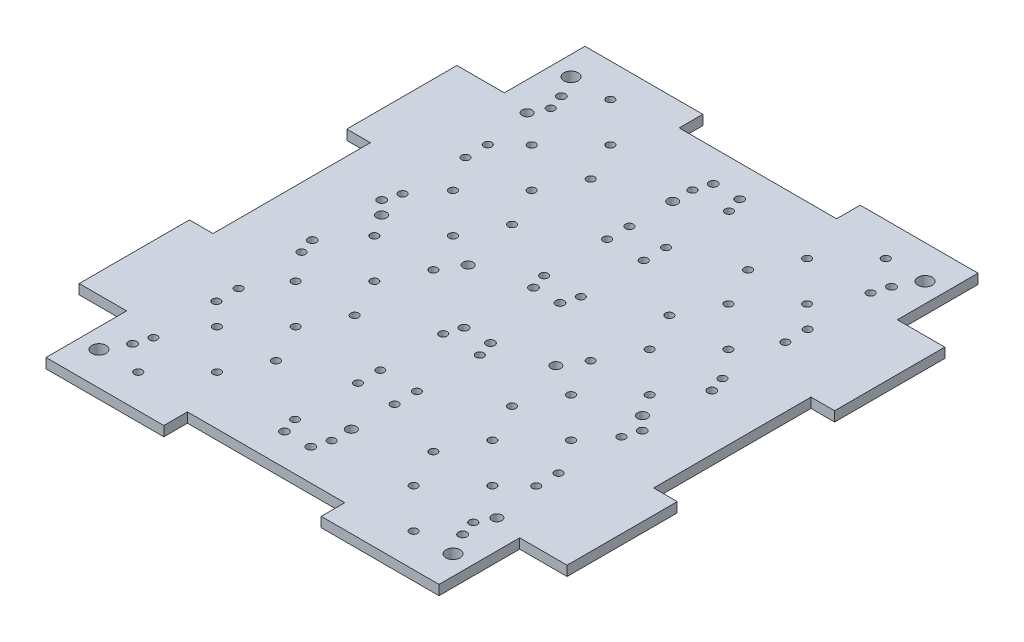
from build123d import *

# Parameters (mm, degrees)
SKETCH1_R                 = 2.286
BOSS_EXTRUDE1_DEPTH       = 3.175
SKETCH2_R                 = 1.35
RASPBERRY_PI_HOLES_DEPTH  = 4.175
SKETCH3_R                 = 1.27
FEATHER_BOARD_HOLES_DEPTH = 4.175
SKETCH4_R                 = 1.6
ARDUINO_UNO_1_DEPTH       = 4.175
SKETCH5_R                 = 1.6
ARDUINO_UNO_2_DEPTH       = 4.175
SKETCH6_R                 = 1.27
CUSTOM_PCB_3_INCH_DEPTH   = 4.175
SKETCH7_R                 = 1.27
CUSTOM_PCB_2_5_INCH_DEPTH = 4.175
SKETCH8_R                 = 1.27
CUSTOM_PCB_2_INCH_DEPTH   = 4.175


with BuildPart() as part:
    # Sketch1 → Boss-Extrude1 (new body)
    with BuildSketch(Plane(origin=(0, 0, 0), x_dir=(1, 0, 0), z_dir=(0, 1, 0))):
        Polygon((-25.4, 86.995), (-63.43142, 86.995), (-63.43142, 60.96), (-78.74, 60.96), (-78.74, 25.4), (-71.12, 25.4), (-71.12, -25.4), (-78.74, -25.4), (-78.74, -60.96), (-63.43142, -60.96), (-63.43142, -86.995), (-25.4, -86.995), (-25.4, -79.375), (25.4, -79.375), (25.4, -86.995), (63.43142, -86.995), (63.43142, -60.96), (78.74, -60.96), (78.74, -25.4), (71.12, -25.4), (71.12, 25.4), (78.74, 25.4), (78.74, 60.96), (63.43142, 60.96), (63.43142, 86.995), (25.4, 86.995), (25.4, 79.375), (-25.4, 79.375), align=None)
        with Locations((-57.15, 76.2)):
            Circle(SKETCH1_R, mode=Mode.SUBTRACT)
        with Locations((57.15, 76.2)):
            Circle(SKETCH1_R, mode=Mode.SUBTRACT)
        with Locations((57.15, -76.2)):
            Circle(SKETCH1_R, mode=Mode.SUBTRACT)
        with Locations((-57.15, -76.2)):
            Circle(SKETCH1_R, mode=Mode.SUBTRACT)
    extrude(amount=BOSS_EXTRUDE1_DEPTH)

    # Sketch2 → Raspberry Pi Holes (cut, through all)
    with BuildSketch(Plane(origin=(0, 3.175, 0), x_dir=(1, 0, 0), z_dir=(0, 1, 0))):
        with Locations((-53.27142, -69.215)):
            Circle(SKETCH2_R)
        with Locations((-4.27142, -69.215)):
            Circle(SKETCH2_R)
        with Locations((-4.27142, -11.215)):
            Circle(SKETCH2_R)
        with Locations((-53.27142, -11.215)):
            Circle(SKETCH2_R)
        with Locations((53.27142, -11.215)):
            Circle(SKETCH2_R)
        with Locations((4.27142, -11.215)):
            Circle(SKETCH2_R)
        with Locations((4.27142, -69.215)):
            Circle(SKETCH2_R)
        with Locations((53.27142, -69.215)):
            Circle(SKETCH2_R)
        with Locations((53.27142, 11.215)):
            Circle(SKETCH2_R)
        with Locations((53.27142, 69.215)):
            Circle(SKETCH2_R)
        with Locations((4.27142, 69.215)):
            Circle(SKETCH2_R)
        with Locations((4.27142, 11.215)):
            Circle(SKETCH2_R)
        with Locations((-4.27142, 11.215)):
            Circle(SKETCH2_R)
        with Locations((-4.27142, 69.215)):
            Circle(SKETCH2_R)
        with Locations((-53.27142, 11.215)):
            Circle(SKETCH2_R)
        with Locations((-53.27142, 69.215)):
            Circle(SKETCH2_R)
    extrude(amount=-RASPBERRY_PI_HOLES_DEPTH, mode=Mode.SUBTRACT)

    # Sketch3 → Feather Board Holes (cut, through all)
    with BuildSketch(Plane(origin=(0, 3.175, 0), x_dir=(1, 0, 0), z_dir=(0, 1, 0))):
        with Locations((-51.63142, -64.135)):
            Circle(SKETCH3_R)
        with Locations((-5.91142, -64.135)):
            Circle(SKETCH3_R)
        with Locations((-5.91142, -43.815)):
            Circle(SKETCH3_R)
        with Locations((-51.63142, -43.815)):
            Circle(SKETCH3_R)
        with Locations((-51.63142, -16.295)):
            Circle(SKETCH3_R)
        with Locations((-51.63142, -36.615)):
            Circle(SKETCH3_R)
        with Locations((-5.91142, -36.615)):
            Circle(SKETCH3_R)
        with Locations((-5.91142, -16.295)):
            Circle(SKETCH3_R)
        with Locations((5.91142, -16.295)):
            Circle(SKETCH3_R)
        with Locations((5.91142, -36.615)):
            Circle(SKETCH3_R)
        with Locations((51.63142, -36.615)):
            Circle(SKETCH3_R)
        with Locations((51.63142, -16.295)):
            Circle(SKETCH3_R)
        with Locations((51.63142, -43.815)):
            Circle(SKETCH3_R)
        with Locations((5.91142, -43.815)):
            Circle(SKETCH3_R)
        with Locations((5.91142, -64.135)):
            Circle(SKETCH3_R)
        with Locations((51.63142, -64.135)):
            Circle(SKETCH3_R)
        with Locations((51.63142, 64.135)):
            Circle(SKETCH3_R)
        with Locations((5.91142, 64.135)):
            Circle(SKETCH3_R)
        with Locations((5.91142, 43.815)):
            Circle(SKETCH3_R)
        with Locations((51.63142, 43.815)):
            Circle(SKETCH3_R)
        with Locations((51.63142, 16.295)):
            Circle(SKETCH3_R)
        with Locations((51.63142, 36.615)):
            Circle(SKETCH3_R)
        with Locations((5.91142, 36.615)):
            Circle(SKETCH3_R)
        with Locations((5.91142, 16.295)):
            Circle(SKETCH3_R)
        with Locations((-5.91142, 16.295)):
            Circle(SKETCH3_R)
        with Locations((-5.91142, 36.615)):
            Circle(SKETCH3_R)
        with Locations((-51.63142, 36.615)):
            Circle(SKETCH3_R)
        with Locations((-51.63142, 16.295)):
            Circle(SKETCH3_R)
        with Locations((-51.63142, 43.815)):
            Circle(SKETCH3_R)
        with Locations((-5.91142, 43.815)):
            Circle(SKETCH3_R)
        with Locations((-5.91142, 64.135)):
            Circle(SKETCH3_R)
        with Locations((-51.63142, 64.135)):
            Circle(SKETCH3_R)
    extrude(amount=-FEATHER_BOARD_HOLES_DEPTH, mode=Mode.SUBTRACT)

    # Sketch4 → Arduino Uno 1 (cut, through all)
    with BuildSketch(Plane(origin=(0, 3.175, 0), x_dir=(1, 0, 0), z_dir=(0, 1, 0))):
        with Locations((5.91142, -57.785)):
            Circle(SKETCH4_R)
        with Locations((21.15142, -6.985)):
            Circle(SKETCH4_R)
        with Locations((49.09142, -6.985)):
            Circle(SKETCH4_R)
        with Locations((54.17142, -59.055)):
            Circle(SKETCH4_R)
    extrude(amount=-ARDUINO_UNO_1_DEPTH, mode=Mode.SUBTRACT)

    # Sketch5 → Arduino Uno 2 (cut, through all)
    with BuildSketch(Plane(origin=(0, 3.175, 0), x_dir=(1, 0, 0), z_dir=(0, 1, 0))):
        with Locations((-5.91142, 57.785)):
            Circle(SKETCH5_R)
        with Locations((-54.17142, 59.055)):
            Circle(SKETCH5_R)
        with Locations((-49.09142, 6.985)):
            Circle(SKETCH5_R)
        with Locations((-21.15142, 6.985)):
            Circle(SKETCH5_R)
    extrude(amount=-ARDUINO_UNO_2_DEPTH, mode=Mode.SUBTRACT)

    # Sketch6 → Custom PCB 3 inch (cut, through all)
    with BuildSketch(Plane(origin=(0, 3.175, 0), x_dir=(1, 0, 0), z_dir=(0, 1, 0))):
        with Locations((44.45, 76.2)):
            Circle(SKETCH6_R)
        with Locations((-44.45, 76.2)):
            Circle(SKETCH6_R)
        with Locations((44.45, 50.8)):
            Circle(SKETCH6_R)
        with Locations((-44.45, 50.8)):
            Circle(SKETCH6_R)
        with Locations((44.45, 25.4)):
            Circle(SKETCH6_R)
        with Locations((-44.45, 25.4)):
            Circle(SKETCH6_R)
        with Locations((44.45, 0)):
            Circle(SKETCH6_R)
        with Locations((-44.45, 0)):
            Circle(SKETCH6_R)
        with Locations((44.45, -25.4)):
            Circle(SKETCH6_R)
        with Locations((-44.45, -25.4)):
            Circle(SKETCH6_R)
        with Locations((44.45, -50.8)):
            Circle(SKETCH6_R)
        with Locations((-44.45, -50.8)):
            Circle(SKETCH6_R)
        with Locations((44.45, -76.2)):
            Circle(SKETCH6_R)
        with Locations((-44.45, -76.2)):
            Circle(SKETCH6_R)
    extrude(amount=-CUSTOM_PCB_3_INCH_DEPTH, mode=Mode.SUBTRACT)

    # Sketch7 → Custom PCB 2.5 inch (cut, through all)
    with BuildSketch(Plane(origin=(0, 3.175, 0), x_dir=(1, 0, 0), z_dir=(0, 1, 0))):
        with Locations((-31.75, -63.5)):
            Circle(SKETCH7_R)
        with Locations((31.75, -63.5)):
            Circle(SKETCH7_R)
        with Locations((31.75, -38.1)):
            Circle(SKETCH7_R)
        with Locations((-31.75, -38.1)):
            Circle(SKETCH7_R)
        with Locations((31.75, -12.7)):
            Circle(SKETCH7_R)
        with Locations((-31.75, -12.7)):
            Circle(SKETCH7_R)
        with Locations((31.75, 12.7)):
            Circle(SKETCH7_R)
        with Locations((-31.75, 12.7)):
            Circle(SKETCH7_R)
        with Locations((31.75, 38.1)):
            Circle(SKETCH7_R)
        with Locations((-31.75, 38.1)):
            Circle(SKETCH7_R)
        with Locations((31.75, 63.5)):
            Circle(SKETCH7_R)
        with Locations((-31.75, 63.5)):
            Circle(SKETCH7_R)
    extrude(amount=-CUSTOM_PCB_2_5_INCH_DEPTH, mode=Mode.SUBTRACT)

    # Sketch8 → Custom PCB 2 inch (cut, through all)
    with BuildSketch(Plane(origin=(0, 3.175, 0), x_dir=(1, 0, 0), z_dir=(0, 1, 0))):
        with Locations((-25.4, -50.8)):
            Circle(SKETCH8_R)
        with Locations((25.4, -50.8)):
            Circle(SKETCH8_R)
        with Locations((-25.4, -25.4)):
            Circle(SKETCH8_R)
        with Locations((25.4, -25.4)):
            Circle(SKETCH8_R)
        with Locations((-25.4, 0)):
            Circle(SKETCH8_R)
        with Locations((25.4, 0)):
            Circle(SKETCH8_R)
        with Locations((-25.4, 25.4)):
            Circle(SKETCH8_R)
        with Locations((25.4, 25.4)):
            Circle(SKETCH8_R)
        with Locations((-25.4, 50.8)):
            Circle(SKETCH8_R)
        with Locations((25.4, 50.8)):
            Circle(SKETCH8_R)
    extrude(amount=-CUSTOM_PCB_2_INCH_DEPTH, mode=Mode.SUBTRACT)


solid = part.part
